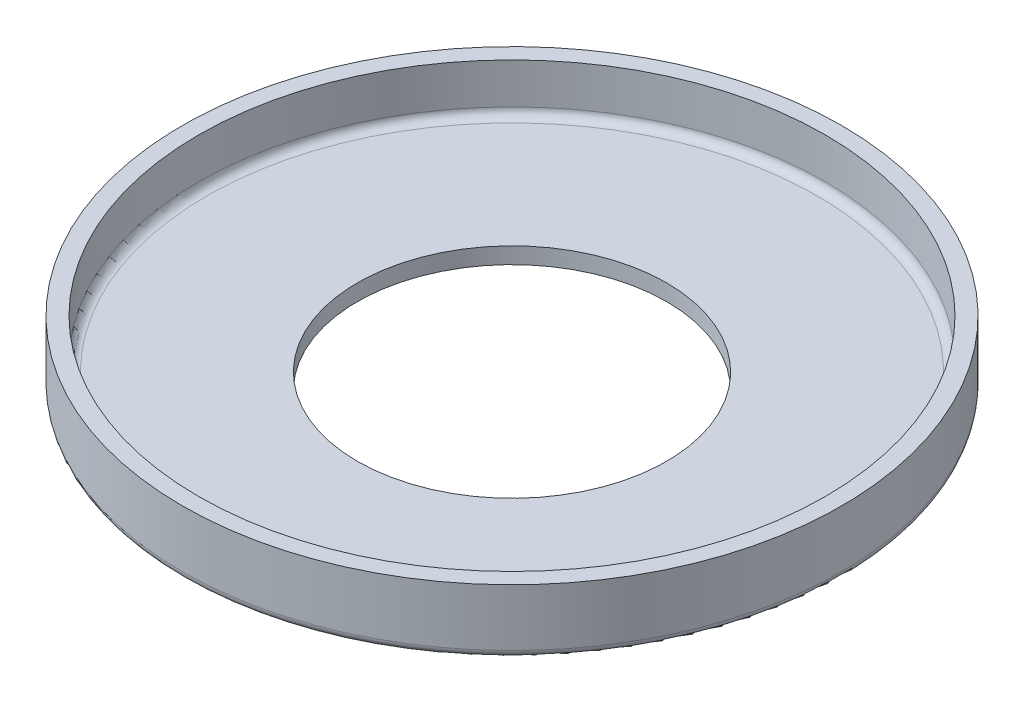
from build123d import *

# Parameters (mm, degrees)
SKETCH1_R           = 40.5
SKETCH1_R_2         = 19
BOSS_EXTRUDE1_DEPTH = 2
SKETCH1_3_R         = 40.5
SKETCH1_3_R_2       = 38.5
BOSS_EXTRUDE2_DEPTH = 8
FILLET1_R           = 1
FILLET2_R           = 1


with BuildPart() as part:
    # Sketch1 → Boss-Extrude1 (new body)
    with BuildSketch(Plane(origin=(0, 0, 0), x_dir=(1, 0, 0), z_dir=(0, 1, 0))):
        Circle(SKETCH1_R)
        Circle(SKETCH1_R_2, mode=Mode.SUBTRACT)
    extrude(amount=BOSS_EXTRUDE1_DEPTH)

    # Sketch1_3 → Boss-Extrude2 (add)
    with BuildSketch(Plane(origin=(0, 0, 0), x_dir=(1, 0, 0), z_dir=(0, 1, 0))):
        Circle(SKETCH1_3_R)
        Circle(SKETCH1_3_R_2, mode=Mode.SUBTRACT)
    extrude(amount=BOSS_EXTRUDE2_DEPTH)

    # Fillet1
    fillet1_edges = [part.edges().sort_by_distance(p)[0] for p in [
        (-40.5, 0, 0),
    ]]
    fillet(fillet1_edges, radius=FILLET1_R)

    # Fillet2
    fillet2_edges = [part.edges().sort_by_distance(p)[0] for p in [
        (-38.5, 2, 0),
    ]]
    fillet(fillet2_edges, radius=FILLET2_R)


solid = part.part
